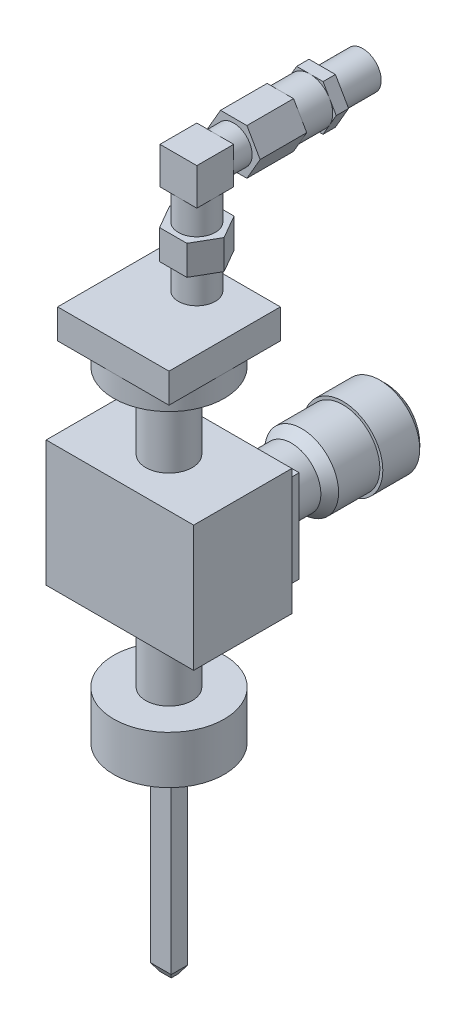
from build123d import *

# Parameters (mm, degrees)
SKETCH1_W            = 3.556
SKETCH1_H            = 2.794
SKETCH1_W_2          = 1.3716
SKETCH1_H_2          = 0.635
BOSS_EXTRUDE1_DEPTH  = 34.29
SKETCH2_R            = 9.525
BOSS_EXTRUDE2_DEPTH  = 8.255
SKETCH3_R            = 4.0005
BOSS_EXTRUDE3_DEPTH  = 13.081
SKETCH4_W            = 25.4
SKETCH4_H            = 16.9037
BOSS_EXTRUDE4_DEPTH  = 21.6662
SKETCH5_R            = 4.0005
BOSS_EXTRUDE5_DEPTH  = 13.081
SKETCH6_R            = 9.525
BOSS_EXTRUDE6_DEPTH  = 3.81
SKETCH7_W            = 19.177
SKETCH7_H            = 19.177
BOSS_EXTRUDE7_DEPTH  = 5.08
SKETCH8_R            = 3.175
BOSS_EXTRUDE8_DEPTH  = 15.494
SKETCH9_W            = 6.35
SKETCH9_H            = 6.35
BOSS_EXTRUDE9_DEPTH  = 6.35
SKETCH10_R           = 3.175
BOSS_EXTRUDE10_DEPTH = 3.175
BOSS_EXTRUDE11_DEPTH = 15.24
SKETCH12_R           = 3.175
BOSS_EXTRUDE12_DEPTH = 6.985
SKETCH13_W           = 15.9004
SKETCH13_H           = 15.875
BOSS_EXTRUDE13_DEPTH = 2.54
BOSS_EXTRUDE15_DEPTH = 2.54
CUT_EXTRUDE1_DEPTH   = 15
CUT_EXTRUDE2_DEPTH   = 15
FILLET1_R            = 1.27
SKETCH22_R           = 2.54
SKETCH22_R_2         = 0.127
CUT_EXTRUDE3_DEPTH   = 3.81
SKETCH22_3_R         = 0.127
CUT_EXTRUDE4_DEPTH   = 12.7
CUT_EXTRUDE7_DEPTH   = 5.08


with BuildPart() as part:
    # Sketch1 → Boss-Extrude1 (new body)
    with BuildSketch(Plane(origin=(0, 0, 0), x_dir=(1, 0, 0), z_dir=(0, 1, 0))):
        with Locations((1.778, -1.397)):
            Rectangle(SKETCH1_W, SKETCH1_H)
        with Locations((1.778, -1.397)):
            Rectangle(SKETCH1_W_2, SKETCH1_H_2, mode=Mode.SUBTRACT)
    extrude(amount=BOSS_EXTRUDE1_DEPTH)

    # Sketch2 → Boss-Extrude2 (add)
    with BuildSketch(Plane(origin=(0, 34.29, 0), x_dir=(1, 0, 0), z_dir=(0, 1, 0))):
        with Locations((1.778, -1.397)):
            Circle(SKETCH2_R)
    extrude(amount=BOSS_EXTRUDE2_DEPTH)

    # Sketch3 → Boss-Extrude3 (add)
    with BuildSketch(Plane(origin=(0, 42.545, 0), x_dir=(1, 0, 0), z_dir=(0, 1, 0))):
        with Locations((1.778, -1.397)):
            Circle(SKETCH3_R)
    extrude(amount=BOSS_EXTRUDE3_DEPTH)

    # Sketch4 → Boss-Extrude4 (add)
    with BuildSketch(Plane(origin=(0, 55.626, 0), x_dir=(1, 0, 0), z_dir=(0, 1, 0))):
        with Locations((1.778, -1.397)):
            Rectangle(SKETCH4_W, SKETCH4_H)
    extrude(amount=BOSS_EXTRUDE4_DEPTH)

    # Sketch5 → Boss-Extrude5 (add)
    with BuildSketch(Plane(origin=(0, 77.2922, 0), x_dir=(1, 0, 0), z_dir=(0, 1, 0))):
        with Locations((1.778, -1.397)):
            Circle(SKETCH5_R)
    extrude(amount=BOSS_EXTRUDE5_DEPTH)

    # Sketch6 → Boss-Extrude6 (add)
    with BuildSketch(Plane(origin=(0, 90.3732, 0), x_dir=(1, 0, 0), z_dir=(0, 1, 0))):
        with Locations((1.778, -1.397)):
            Circle(SKETCH6_R)
    extrude(amount=BOSS_EXTRUDE6_DEPTH)

    # Sketch7 → Boss-Extrude7 (add)
    with BuildSketch(Plane(origin=(0, 94.1832, 0), x_dir=(1, 0, 0), z_dir=(0, 1, 0))):
        with Locations((1.778, -1.397)):
            Rectangle(SKETCH7_W, SKETCH7_H)
    extrude(amount=BOSS_EXTRUDE7_DEPTH)

    # Sketch8 → Boss-Extrude8 (add)
    with BuildSketch(Plane(origin=(0, 99.2632, 0), x_dir=(1, 0, 0), z_dir=(0, 1, 0))):
        with Locations((1.778, 3.39725)):
            Circle(SKETCH8_R)
    extrude(amount=BOSS_EXTRUDE8_DEPTH)

    # Sketch9 → Boss-Extrude9 (add)
    with BuildSketch(Plane(origin=(0, 114.7572, 0), x_dir=(1, 0, 0), z_dir=(0, 1, 0))):
        with Locations((1.778, 3.39725)):
            Rectangle(SKETCH9_W, SKETCH9_H)
    extrude(amount=BOSS_EXTRUDE9_DEPTH)

    # Sketch10 → Boss-Extrude10 (add)
    with BuildSketch(Plane(origin=(0, 0, -6.57225), x_dir=(-1, 0, 0), z_dir=(0, 0, -1))):
        with Locations((-1.778, 117.9322)):
            Circle(SKETCH10_R)
    extrude(amount=BOSS_EXTRUDE10_DEPTH)

    # Sketch11 → Boss-Extrude11 (add)
    with BuildSketch(Plane(origin=(0, 0, -9.74725), x_dir=(-1, 0, 0), z_dir=(0, 0, -1))):
        Polygon((0.49502801, 113.9952), (2.76805602, 117.9322), (0.49502801, 121.8692), (-4.05102801, 121.8692), (-6.32405602, 117.9322), (-4.05102801, 113.9952), align=None)
    extrude(amount=BOSS_EXTRUDE11_DEPTH)

    # Sketch12 → Boss-Extrude12 (add)
    with BuildSketch(Plane(origin=(0, 0, -24.98725), x_dir=(-1, 0, 0), z_dir=(0, 0, -1))):
        with Locations((-1.778, 117.9322)):
            Circle(SKETCH12_R)
    extrude(amount=BOSS_EXTRUDE12_DEPTH)

    # Sketch13 → Boss-Extrude13 (add)
    with BuildSketch(Plane(origin=(0, 0, -7.05485), x_dir=(-1, 0, 0), z_dir=(0, 0, -1))):
        with Locations((-5.2578, 66.8147)):
            Rectangle(SKETCH13_W, SKETCH13_H)
    extrude(amount=BOSS_EXTRUDE13_DEPTH)

    # Sketch16 → Revolve1 (revolve)
    with BuildSketch(Plane(origin=(5.2578, 0, 0), x_dir=(0, 0, -1), z_dir=(1, 0, 0))):
        with BuildLine():
            Line((9.59485, 66.8147), (9.59485, 71.8947))
            Line((9.59485, 71.8947), (16.19885, 71.8947))
            Line((16.19885, 71.8947), (17.97685, 73.1647))
            Line((17.97685, 73.1647), (25.08885, 73.1647))
            Line((25.08885, 73.1647), (25.08885, 73.6727))
            Line((25.08885, 73.6727), (31.43885, 73.6727))
            ThreePointArc((31.43885, 73.6727), (33.469498821, 71.155053903), (34.48685, 68.0847))
            Line((34.48685, 68.0847), (34.74085, 68.0847))
            Line((34.74085, 68.0847), (34.74085, 66.8147))
            Line((34.74085, 66.8147), (9.59485, 66.8147))
        make_face()
    revolve(axis=Axis((5.2578, 66.8147, -9.59485), (0, 0, -1)))

    # Sketch17 → Boss-Extrude15 (add, symmetric)
    with BuildSketch(Plane(origin=(0, 107.0102, 0), x_dir=(1, 0, 0), z_dir=(0, 1, 0))):
        Polygon((6.470702988, 3.39725), (4.124351494, 7.46125), (-0.568351494, 7.46125), (-2.914702988, 3.39725), (-0.568351494, -0.66675), (4.124351494, -0.66675), align=None)
    extrude(amount=BOSS_EXTRUDE15_DEPTH, both=True)

    # Sketch20 → Cut-Extrude1 (cut)
    with BuildSketch(Plane.ZY):
        Polygon((0, 0), (0.762, 0), (0, 1.27), align=None)
        Polygon((2.794, 0), (2.794, 1.27), (2.032, 0), align=None)
    extrude(amount=-CUT_EXTRUDE1_DEPTH, mode=Mode.SUBTRACT)

    # Sketch21 → Cut-Extrude2 (cut)
    with BuildSketch(Plane(origin=(0, 0, 0), x_dir=(-1, 0, 0), z_dir=(0, 0, -1))):
        Polygon((-3.556, 1.27), (-3.556, 0), (-2.794, 0), align=None)
        Polygon((0, 1.27), (-0.762, 0), (0, 0), align=None)
    extrude(amount=-CUT_EXTRUDE2_DEPTH, mode=Mode.SUBTRACT)

    # Fillet1
    fillet1_edges = [part.edges().sort_by_distance(p)[0] for p in [
        (3.556, 34.29, 1.397),
        (1.778, 34.29, 2.794),
        (0, 34.29, 1.397),
        (1.778, 34.29, 0),
    ]]
    fillet(fillet1_edges, radius=FILLET1_R)

    # Sketch22 → Cut-Extrude3 (cut)
    with BuildSketch(Plane(origin=(0, 0, -31.97225), x_dir=(-1, 0, 0), z_dir=(0, 0, -1))):
        with Locations((-1.778, 117.9322)):
            Circle(SKETCH22_R)
        with Locations((-1.778, 117.9322)):
            Circle(SKETCH22_R_2, mode=Mode.SUBTRACT)
    extrude(amount=-CUT_EXTRUDE3_DEPTH, mode=Mode.SUBTRACT)

    # Sketch22_3 → Cut-Extrude4 (cut)
    with BuildSketch(Plane(origin=(0, 0, -31.97225), x_dir=(-1, 0, 0), z_dir=(0, 0, -1))):
        with Locations((-1.778, 117.9322)):
            Circle(SKETCH22_3_R)
    extrude(amount=-CUT_EXTRUDE4_DEPTH, mode=Mode.SUBTRACT)

    # Sketch25 → Cut-Extrude7 (cut)
    with BuildSketch(Plane.XY.offset(-17.78)):
        with BuildLine():
            Line((-1.63154216, 119.900699749), (-2.76805602, 117.9322))
            Line((-2.76805602, 117.9322), (-1.631542045, 115.963700052))
            ThreePointArc((-1.631542045, 115.963700052), (-2.159, 117.932199885), (-1.63154216, 119.900699749))
        make_face()
        with BuildLine():
            ThreePointArc((1.778, 113.9952), (-0.190500026, 114.522658), (-1.631542045, 115.963700052))
            Line((-1.631542045, 115.963700052), (-0.49502801, 113.9952))
            Line((-0.49502801, 113.9952), (1.778, 113.9952))
        make_face()
        with BuildLine():
            Line((-0.49502801, 121.8692), (-1.63154216, 119.900699749))
            ThreePointArc((-1.63154216, 119.900699749), (-0.190500126, 121.341741942), (1.778, 121.8692))
            Line((1.778, 121.8692), (-0.49502801, 121.8692))
        make_face()
        with BuildLine():
            ThreePointArc((5.18754197, 115.963699923), (3.746499961, 114.522657963), (1.778, 113.9952))
            Line((1.778, 113.9952), (4.05102801, 113.9952))
            Line((4.05102801, 113.9952), (5.18754197, 115.963699923))
        make_face()
        with BuildLine():
            Line((4.05102801, 121.8692), (1.778, 121.8692))
            ThreePointArc((1.778, 121.8692), (3.746499994, 121.341742018), (5.187542007, 119.900700013))
            Line((5.187542007, 119.900700013), (4.05102801, 121.8692))
        make_face()
        with BuildLine():
            ThreePointArc((5.187542007, 119.900700013), (5.715, 117.932199963), (5.18754197, 115.963699923))
            Line((5.18754197, 115.963699923), (6.32405602, 117.9322))
            Line((6.32405602, 117.9322), (5.187542007, 119.900700013))
        make_face()
    extrude(amount=-CUT_EXTRUDE7_DEPTH, mode=Mode.SUBTRACT)


solid = part.part
